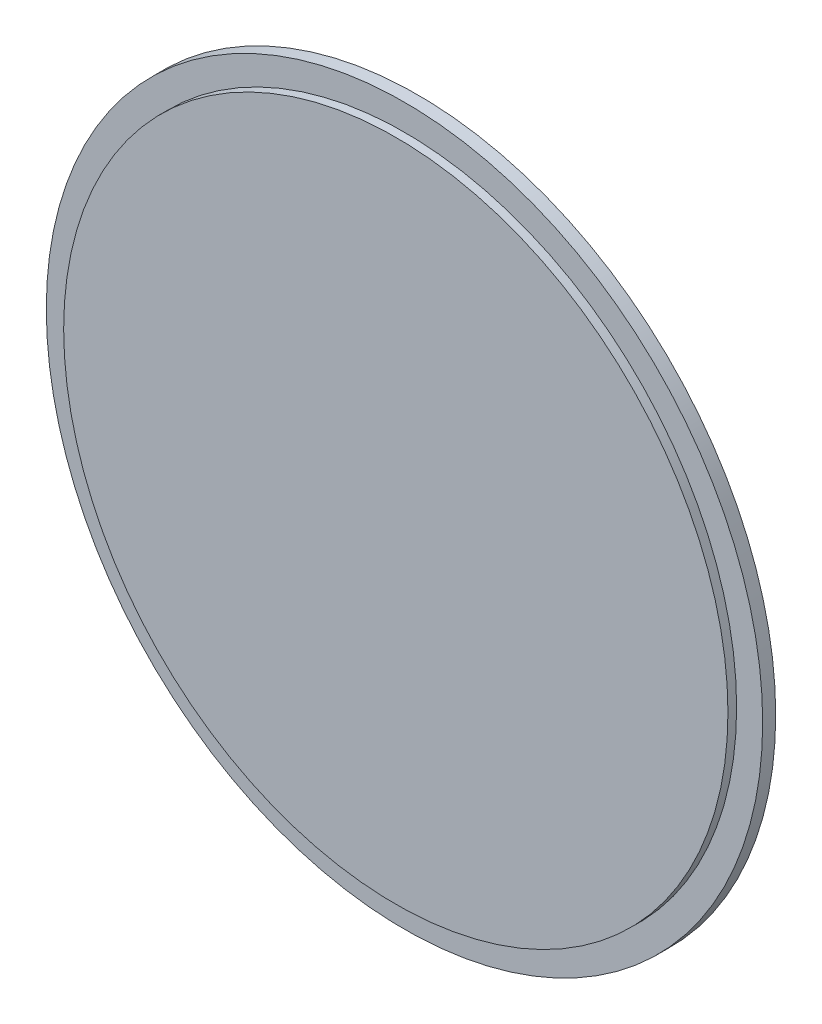
from build123d import *

# Parameters (mm, degrees)
ESBO_O1_R                = 82.5
ESBO_O1_R_2              = 14
RESSALTO_EXTRUS_O1_DEPTH = 3
ESBO_O2_R                = 5.925
RESSALTO_EXTRUS_O2_DEPTH = 8
ESBO_O3_R                = 14
RESSALTO_EXTRUS_O3_DEPTH = 3
ESBO_O4_R                = 10
RESSALTO_EXTRUS_O4_DEPTH = 11
ESBO_O5_R                = 3.05
CORTE_EXTRUS_O1_DEPTH    = 1
ESBO_O6_R                = 76.5
RESSALTO_EXTRUS_O5_DEPTH = 2


with BuildPart() as part:
    # Esboço1 → Ressalto-extrusão1 (new body)
    with BuildSketch(Plane.XY):
        Circle(ESBO_O1_R)
        Circle(ESBO_O1_R_2, mode=Mode.SUBTRACT)
    extrude(amount=RESSALTO_EXTRUS_O1_DEPTH)

    # Esboço2 → Ressalto-extrusão2 (add)
    with BuildSketch(Plane(origin=(0, 0, 0), x_dir=(-1, 0, 0), z_dir=(0, 0, -1))):
        with Locations((-55.155254038, 14.383947721)):
            Circle(ESBO_O2_R)
        with Locations((40.034491152, 40.573877288)):
            Circle(ESBO_O2_R)
        with Locations((15.120762886, -54.957825009)):
            Circle(ESBO_O2_R)
    extrude(amount=RESSALTO_EXTRUS_O2_DEPTH)

    # Esboço3 → Ressalto-extrusão3 (add)
    with BuildSketch(Plane.XY.offset(3)):
        Circle(ESBO_O3_R)
    extrude(amount=-RESSALTO_EXTRUS_O3_DEPTH)

    # Esboço4 → Ressalto-extrusão4 (add)
    with BuildSketch(Plane.XY.offset(3)):
        Circle(ESBO_O4_R)
    extrude(amount=-RESSALTO_EXTRUS_O4_DEPTH)

    # Esboço5 → Corte-extrusão1 (cut)
    with BuildSketch(Plane(origin=(0, 0, -8), x_dir=(-1, 0, 0), z_dir=(0, 0, -1))):
        Circle(ESBO_O5_R)
    extrude(amount=-CORTE_EXTRUS_O1_DEPTH, mode=Mode.SUBTRACT)

    # Esboço6 → Ressalto-extrusão5 (add)
    with BuildSketch(Plane.XY.offset(3)):
        Circle(ESBO_O6_R)
    extrude(amount=RESSALTO_EXTRUS_O5_DEPTH)


solid = part.part
